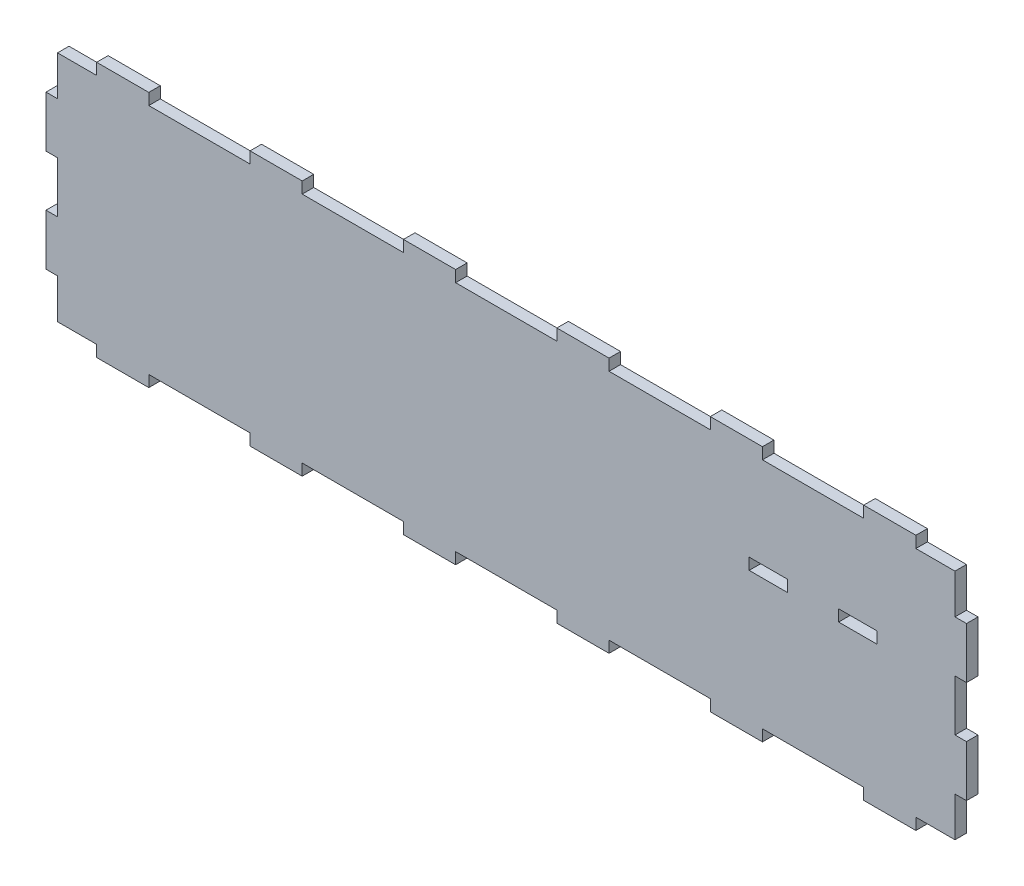
from build123d import *

# Parameters (mm, degrees)
SKETCH1_W             = 457.2
SKETCH1_H             = 127
BOSS_EXTRUDE1_DEPTH   = 5.715
SKETCH2_W             = 19.05
SKETCH2_H             = 5.715
LED_MOUNT_HOLES_DEPTH = 6.715
SKETCH4_W             = 5.715
SKETCH4_H             = 25.4
CUT_EXTRUDE2_DEPTH    = 6.715
SKETCH5_W             = 50.8
SKETCH5_H             = 5.6642
SKETCH5_W_2           = 25.4
SKETCH5_H_2           = 5.715
CUT_EXTRUDE3_DEPTH    = 6.715
SKETCH6_W             = 0.254
SKETCH6_H             = 5.715
SKETCH6_H_2           = 5.6642
BOSS_EXTRUDE2_DEPTH   = 5.715


with BuildPart() as part:
    # Sketch1 → Boss-Extrude1 (new body)
    with BuildSketch(Plane.XY):
        Rectangle(SKETCH1_W, SKETCH1_H)
    extrude(amount=BOSS_EXTRUDE1_DEPTH)

    # Sketch2 → LED Mount Holes (cut, through all)
    with BuildSketch(Plane.XY.offset(5.715)):
        with Locations((174.625, 9.8425)):
            Rectangle(SKETCH2_W, SKETCH2_H)
        with Locations((130.175, 9.8425)):
            Rectangle(SKETCH2_W, SKETCH2_H)
    extrude(amount=-LED_MOUNT_HOLES_DEPTH, mode=Mode.SUBTRACT)

    # Sketch4 → Cut-Extrude2 (cut, through all)
    with BuildSketch(Plane(origin=(0, 0, 0), x_dir=(-1, 0, 0), z_dir=(0, 0, -1))):
        with Locations((-225.7425, 50.8)):
            Rectangle(SKETCH4_W, SKETCH4_H)
        with Locations((-225.7425, 0)):
            Rectangle(SKETCH4_W, SKETCH4_H)
        with Locations((-225.7425, -50.8)):
            Rectangle(SKETCH4_W, SKETCH4_H)
    cut_extrude2 = extrude(amount=-CUT_EXTRUDE2_DEPTH, mode=Mode.SUBTRACT)

    # Mirror1: Cut-Extrude2 across plane
    add(cut_extrude2.mirror(Plane(origin=(0, 0, 0), x_dir=(0, 0, 1), z_dir=(1, 0, 0))), mode=Mode.SUBTRACT)

    # Sketch5 → Cut-Extrude3 (cut, through all)
    with BuildSketch(Plane(origin=(0, 0, 0), x_dir=(-1, 0, 0), z_dir=(0, 0, -1))):
        with Locations((-152.4, 60.6679)):
            Rectangle(SKETCH5_W, SKETCH5_H)
        with Locations((-76.2, 60.6679)):
            Rectangle(SKETCH5_W, SKETCH5_H)
        with Locations((0, 60.6679)):
            Rectangle(SKETCH5_W, SKETCH5_H)
        with Locations((76.2, 60.6679)):
            Rectangle(SKETCH5_W, SKETCH5_H)
        with Locations((152.4, 60.6679)):
            Rectangle(SKETCH5_W, SKETCH5_H)
        with Locations((228.6, 60.6679)):
            Rectangle(SKETCH5_W, SKETCH5_H)
        with Locations((-215.9, 60.6425)):
            Rectangle(SKETCH5_W_2, SKETCH5_H_2)
    cut_extrude3 = extrude(amount=-CUT_EXTRUDE3_DEPTH, mode=Mode.SUBTRACT)

    # Sketch6 → Boss-Extrude2 (add)
    with BuildSketch(Plane(origin=(0, 0, 0), x_dir=(-1, 0, 0), z_dir=(0, 0, -1))):
        with Locations((-203.327, 60.6425)):
            Rectangle(SKETCH6_W, SKETCH6_H)
        with Locations((-177.673, 60.6425)):
            Rectangle(SKETCH6_W, SKETCH6_H)
        with Locations((-127.127, 60.6679)):
            Rectangle(SKETCH6_W, SKETCH6_H_2)
        with Locations((-101.473, 60.6679)):
            Rectangle(SKETCH6_W, SKETCH6_H_2)
        with Locations((-50.927, 60.6679)):
            Rectangle(SKETCH6_W, SKETCH6_H_2)
        with Locations((-25.273, 60.6679)):
            Rectangle(SKETCH6_W, SKETCH6_H_2)
        with Locations((25.273, 60.6679)):
            Rectangle(SKETCH6_W, SKETCH6_H_2)
        with Locations((50.927, 60.6679)):
            Rectangle(SKETCH6_W, SKETCH6_H_2)
        with Locations((101.473, 60.6679)):
            Rectangle(SKETCH6_W, SKETCH6_H_2)
        with Locations((127.127, 60.6679)):
            Rectangle(SKETCH6_W, SKETCH6_H_2)
        with Locations((177.673, 60.6679)):
            Rectangle(SKETCH6_W, SKETCH6_H_2)
        with Locations((203.327, 60.6679)):
            Rectangle(SKETCH6_W, SKETCH6_H_2)
    boss_extrude2 = extrude(amount=-BOSS_EXTRUDE2_DEPTH)

    # Mirror2: Cut-Extrude3, Boss-Extrude2 across plane
    add(cut_extrude3.mirror(Plane.ZX), mode=Mode.SUBTRACT)
    add(boss_extrude2.mirror(Plane.ZX))


solid = part.part
